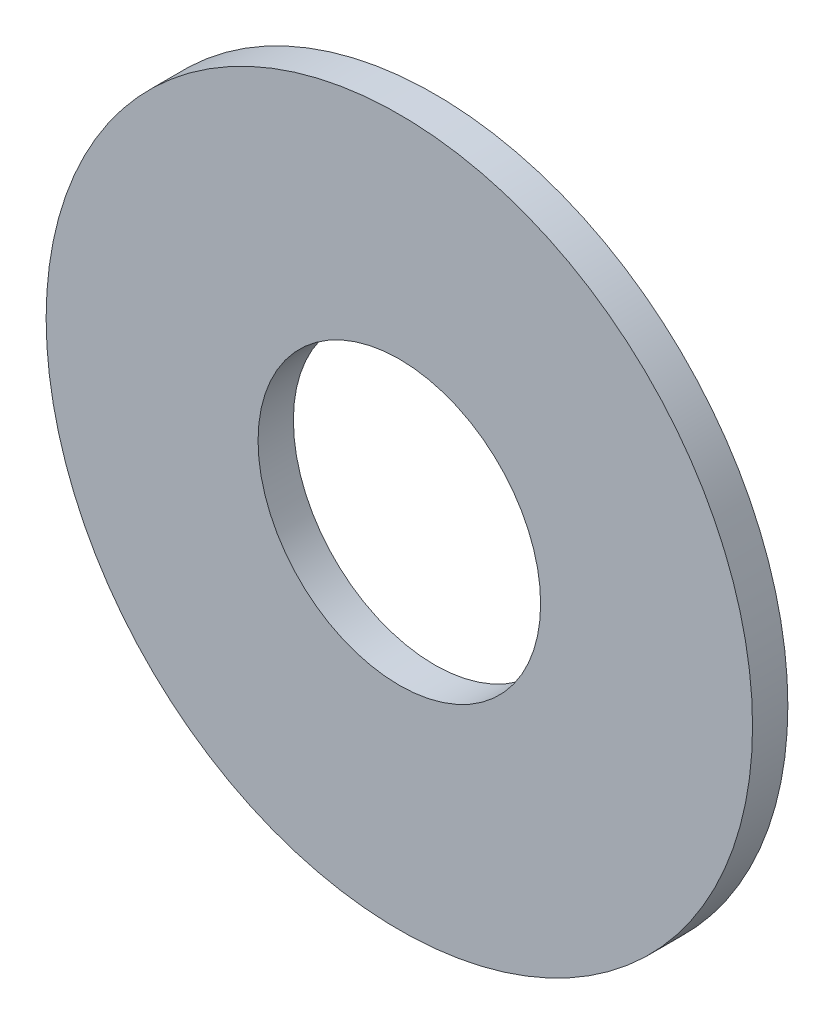
from build123d import *

# Parameters (mm, degrees)
SKETCH_1_R      = 15
SKETCH_1_R_2    = 6
EXTRUDE_1_DEPTH = 1.5


with BuildPart() as part:
    # Эскиз1 → Бобышка-Вытянуть1 (new body)
    with BuildSketch(Plane.XY):
        Circle(SKETCH_1_R)
        Circle(SKETCH_1_R_2, mode=Mode.SUBTRACT)
    extrude(amount=EXTRUDE_1_DEPTH)


solid = part.part
